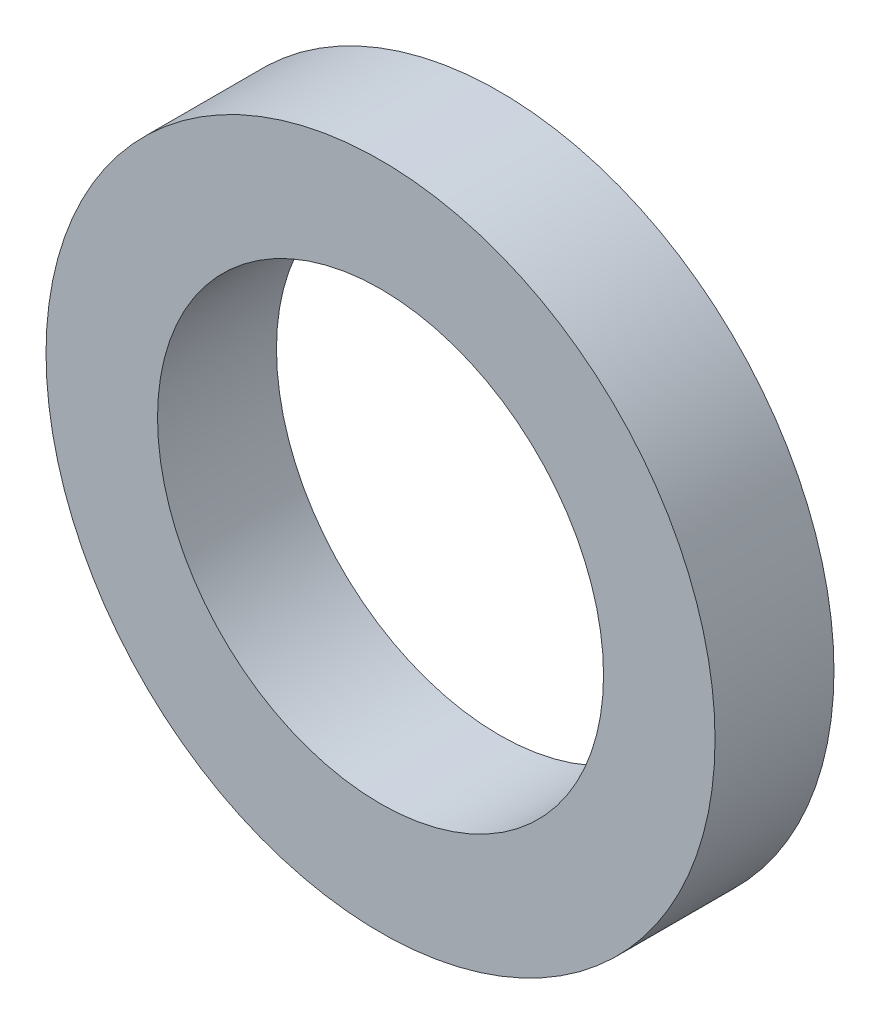
from build123d import *

# Parameters (mm, degrees)
SKETCH_1_R      = 4.5
SKETCH_1_R_2    = 3
EXTRUDE_1_DEPTH = 1.6


with BuildPart() as part:
    # 草图1 → 凸台-拉伸1 (new body)
    with BuildSketch(Plane.XY):
        Circle(SKETCH_1_R)
        Circle(SKETCH_1_R_2, mode=Mode.SUBTRACT)
    extrude(amount=EXTRUDE_1_DEPTH)


solid = part.part
